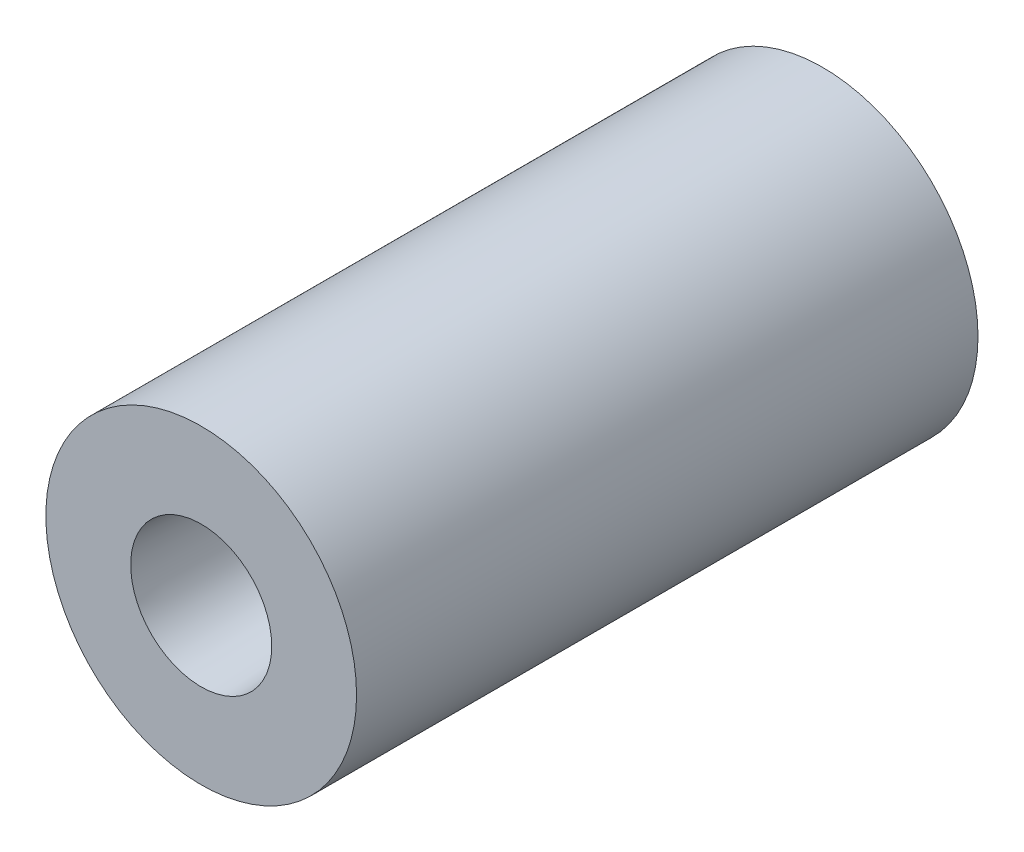
from build123d import *

# Parameters (mm, degrees)
SKETCH1_R           = 5
BOSS_EXTRUDE1_DEPTH = 20
SKETCH2_R           = 2.27
CUT_EXTRUDE1_DEPTH  = 5.68
CUT_EXTRUDE1_TAPER  = 3.074
SKETCH7_R           = 1
CUT_EXTRUDE2_DEPTH  = 21
SKETCH9_R           = 2.27
CUT_EXTRUDE3_DEPTH  = 5.68
CUT_EXTRUDE3_TAPER  = 3.074


with BuildPart() as part:
    # Sketch1 → Boss-Extrude1 (new body)
    with BuildSketch(Plane.XY):
        Circle(SKETCH1_R)
    extrude(amount=BOSS_EXTRUDE1_DEPTH)

    # Sketch2 → Cut-Extrude1 (cut)
    with BuildSketch(Plane.XY):
        Circle(SKETCH2_R)
    extrude(amount=CUT_EXTRUDE1_DEPTH, taper=CUT_EXTRUDE1_TAPER, mode=Mode.SUBTRACT)

    # Sketch7 → Cut-Extrude2 (cut, through all)
    with BuildSketch(Plane.XY):
        Circle(SKETCH7_R)
    extrude(amount=CUT_EXTRUDE2_DEPTH, mode=Mode.SUBTRACT)

    # Sketch9 → Cut-Extrude3 (cut)
    with BuildSketch(Plane.XY.offset(20)):
        Circle(SKETCH9_R)
    extrude(amount=-CUT_EXTRUDE3_DEPTH, taper=CUT_EXTRUDE3_TAPER, mode=Mode.SUBTRACT)


solid = part.part
